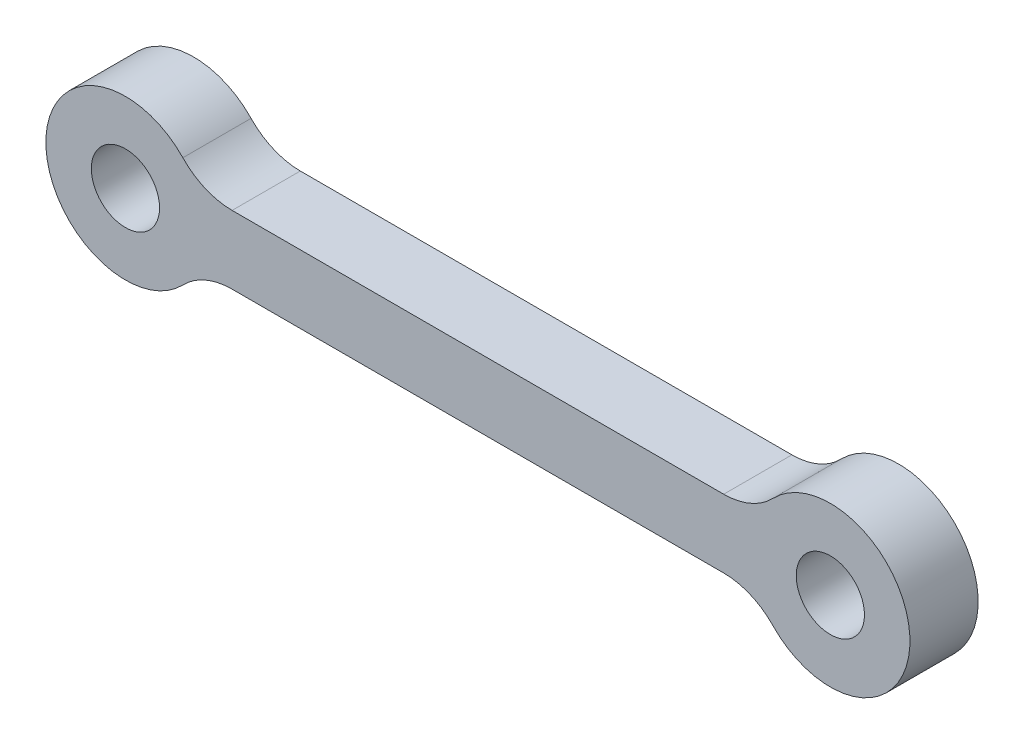
from build123d import *

# Parameters (mm, degrees)
SKETCH1_R           = 3.5
SKETCH1_R_2         = 1.5
BOSS_EXTRUDE1_DEPTH = 1.5
FILLET1_R           = 3


with BuildPart() as part:
    # Sketch1 → Boss-Extrude1 (new body, symmetric)
    with BuildSketch(Plane.XY):
        with Locations((-15.5, 0)):
            Circle(SKETCH1_R)
        with Locations((-15.5, 0)):
            Circle(SKETCH1_R_2, mode=Mode.SUBTRACT)
        with BuildLine():
            Line((12.33772234, 1.5), (-12.33772234, 1.5))
            ThreePointArc((-12.33772234, 1.5), (-12.085474278, 0.768774411), (-12, 0))
            ThreePointArc((-12, 0), (-12.085474278, -0.768774411), (-12.33772234, -1.5))
            Line((-12.33772234, -1.5), (12.33772234, -1.5))
            ThreePointArc((12.33772234, -1.5), (12, 0), (12.33772234, 1.5))
        make_face()
        with Locations((15.5, 0)):
            Circle(SKETCH1_R)
        with Locations((15.5, 0)):
            Circle(SKETCH1_R_2, mode=Mode.SUBTRACT)
    extrude(amount=BOSS_EXTRUDE1_DEPTH, both=True)

    # Fillet1
    fillet1_edges = [part.edges().sort_by_distance(p)[0] for p in [
        (-12.33772234, 1.5, 0),
        (12.33772234, 1.5, 0),
        (12.33772234, -1.5, 0),
        (-12.33772234, -1.5, 0),
    ]]
    fillet(fillet1_edges, radius=FILLET1_R)


solid = part.part
